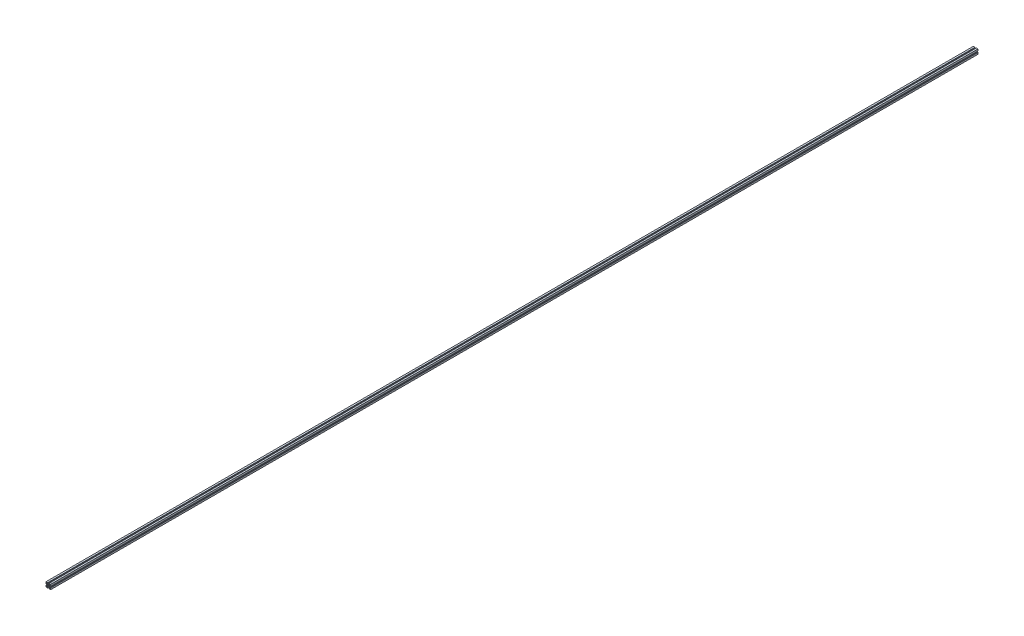
from build123d import *

# Parameters (mm, degrees)
SKETCH_B02_1_R     = 6.05
SKETCH_B02_1_W     = 4.5
SKETCH_B02_1_H     = 4.5
EXTRUDE1_DEPTH     = 6000
CUT_EXTRUDE1_DEPTH = 6001
CIRPATTERN1_COUNT  = 4
CUT_EXTRUDE2_DEPTH = 6001
CIRPATTERN2_COUNT  = 4


with BuildPart() as part:
    # Sketch B02-1 → Extrude1 (new body)
    with BuildSketch(Plane.XY):
        Polygon((-13, -7.265685), (-11.634315, -7.265685), (-8.3, -3.931371213), (-8.3, 3.931371213), (-11.634315, 7.265685), (-13, 7.265685), (-13, 4), (-15, 4), (-15, 15), (-4, 15), (-4, 13), (-7.265685, 13), (-7.265685, 11.634315), (-3.931371213, 8.3), (3.931371213, 8.3), (7.265685, 11.634315), (7.265685, 13), (4, 13), (4, 15), (15, 15), (15, 4), (13, 4), (13, 7.265685), (11.634315, 7.265685), (8.3, 3.931371213), (8.3, -3.931371213), (11.634315, -7.265685), (13, -7.265685), (13, -4), (15, -4), (15, -15), (4, -15), (4, -13), (7.265685, -13), (7.265685, -11.634315), (3.931371213, -8.3), (-3.931371213, -8.3), (-7.265685, -11.634315), (-7.265685, -13), (-4, -13), (-4, -15), (-15, -15), (-15, -4), (-13, -4), align=None)
        Circle(SKETCH_B02_1_R, mode=Mode.SUBTRACT)
        with Locations((-11.25, -11.25)):
            Rectangle(SKETCH_B02_1_W, SKETCH_B02_1_H, mode=Mode.SUBTRACT)
        with Locations((-11.25, 11.25)):
            Rectangle(SKETCH_B02_1_W, SKETCH_B02_1_H, mode=Mode.SUBTRACT)
        with Locations((11.25, -11.25)):
            Rectangle(SKETCH_B02_1_W, SKETCH_B02_1_H, mode=Mode.SUBTRACT)
        with Locations((11.25, 11.25)):
            Rectangle(SKETCH_B02_1_W, SKETCH_B02_1_H, mode=Mode.SUBTRACT)
    extrude(amount=-EXTRUDE1_DEPTH)

    # Sketch1 → Cut-Extrude1 (cut, through all)
    with BuildSketch(Plane.XY):
        Polygon((-11.25, 9), (-7.338420268, 5.088420268), (-5.088420268, 7.338420268), (-9, 11.25), align=None)
    cut_extrude1 = extrude(amount=-CUT_EXTRUDE1_DEPTH, mode=Mode.SUBTRACT)

    # CirPattern1: Cut-Extrude1 ×4 about axis
    cirpattern1_axis = Axis((0, 0, 0), (0, 0, 1))
    for i in range(1, CIRPATTERN1_COUNT):
        add(cut_extrude1.rotate(cirpattern1_axis, i * 360 / CIRPATTERN1_COUNT), mode=Mode.SUBTRACT)

    # Sketch2 → Cut-Extrude2 (cut, through all)
    with BuildSketch(Plane.XY):
        Polygon((-4.706074285, 2.456074285), (-6.01620443, 3.76620443), (-3.76620443, 6.01620443), (-2.456074285, 4.706074285), align=None)
    cut_extrude2 = extrude(amount=-CUT_EXTRUDE2_DEPTH, mode=Mode.SUBTRACT)

    # CirPattern2: Cut-Extrude2 ×4 about axis
    cirpattern2_axis = Axis((0, 0, 0), (0, 0, 1))
    for i in range(1, CIRPATTERN2_COUNT):
        add(cut_extrude2.rotate(cirpattern2_axis, i * 360 / CIRPATTERN2_COUNT), mode=Mode.SUBTRACT)


solid = part.part
